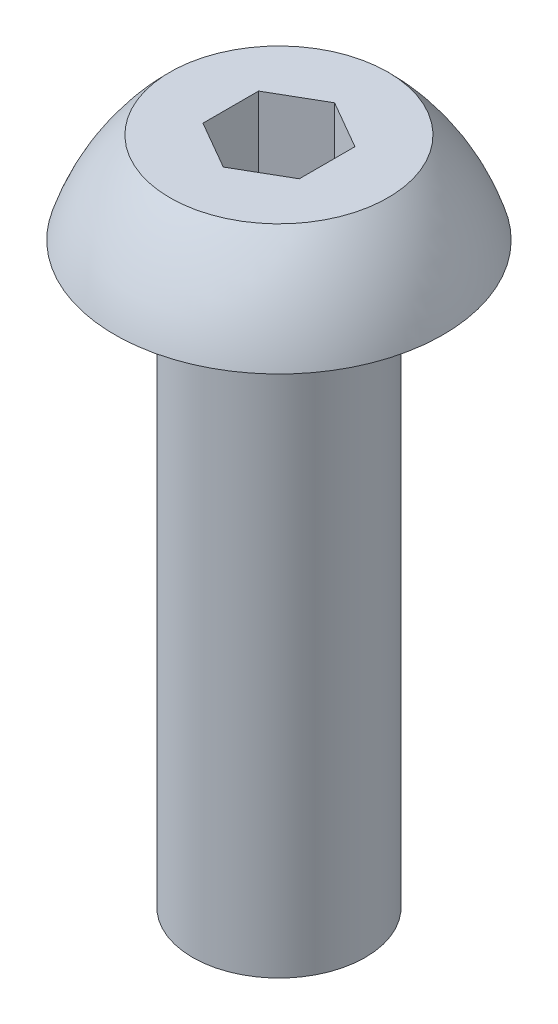
from build123d import *

# Parameters (mm, degrees)
CUT_EXTRUDE1_DEPTH = 1.27


with BuildPart() as part:
    # Sketch1 → Revolve1 (revolve)
    with BuildSketch(Plane.XY):
        with BuildLine():
            Line((-1.4224, 0), (-2.7051, 0))
            ThreePointArc((-2.7051, 0), (-2.343607569, 0.806201731), (-1.79477003, 1.4986))
            Line((-1.79477003, 1.4986), (0, 1.4986))
            Line((0, 1.4986), (0, -9.525))
            Line((0, -9.525), (-1.4224, -9.525))
            Line((-1.4224, -9.525), (-1.4224, 0))
        make_face()
    revolve(axis=Axis((0, -9.525, 0), (0, 1, 0)))

    # Sketch2 → Cut-Extrude1 (cut)
    with BuildSketch(Plane(origin=(0, 1.4986, 0), x_dir=(1, 0, 0), z_dir=(0, 1, 0))):
        Polygon((-0.79375, 0.458271776), (-0.79375, -0.458271776), (0, -0.916543552), (0.79375, -0.458271776), (0.79375, 0.458271776), (0, 0.916543552), align=None)
    extrude(amount=-CUT_EXTRUDE1_DEPTH, mode=Mode.SUBTRACT)


solid = part.part
